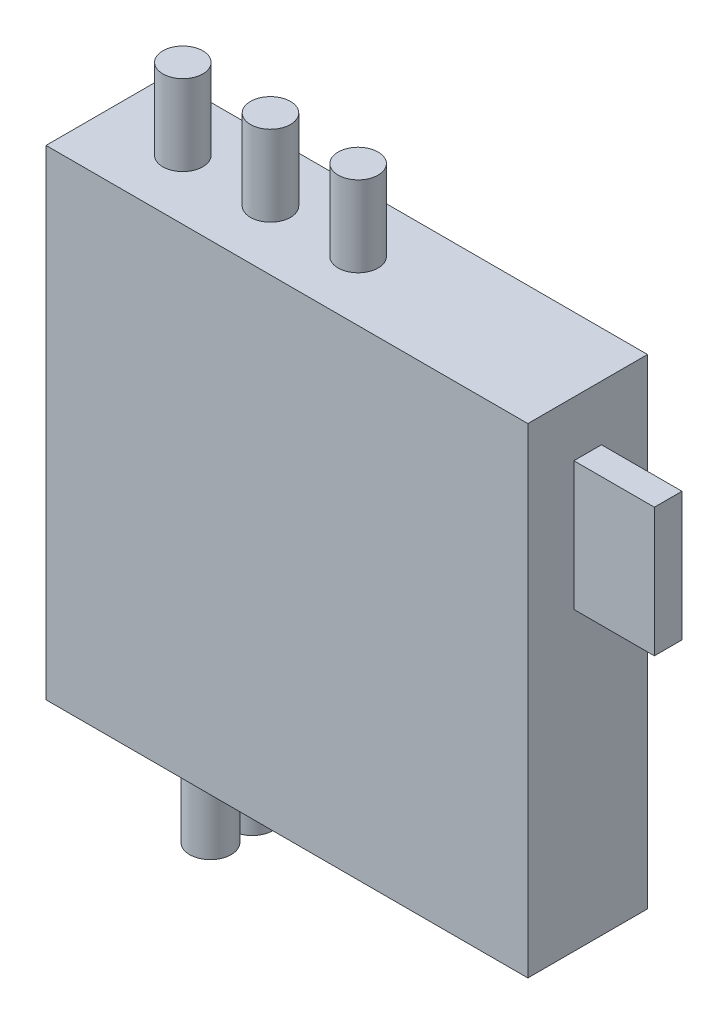
from build123d import *

# Parameters (mm, degrees)
SKETCH1_W           = 52.38
SKETCH1_H           = 13.01
BOSS_EXTRUDE1_DEPTH = 52.2
SKETCH2_R           = 2.26
BOSS_EXTRUDE6_DEPTH = 8.75
SKETCH3_R           = 2.175
BOSS_EXTRUDE7_DEPTH = 8.75
SKETCH4_W           = 3
SKETCH4_H           = 14
BOSS_EXTRUDE8_DEPTH = 8.75


with BuildPart() as part:
    # Sketch1 → Boss-Extrude1 (new body)
    with BuildSketch(Plane(origin=(0, 0, 0), x_dir=(1, 0, 0), z_dir=(0, 1, 0))):
        Rectangle(SKETCH1_W, SKETCH1_H)
    extrude(amount=BOSS_EXTRUDE1_DEPTH)

    # Sketch2 → Boss-Extrude6 (add)
    with BuildSketch(Plane(origin=(0, 0, 0), x_dir=(-1, 0, 0), z_dir=(0, -1, 0))):
        with Locations((12.55, -2.27)):
            Circle(SKETCH2_R)
        with Locations((12.55, 2.27)):
            Circle(SKETCH2_R)
    extrude(amount=BOSS_EXTRUDE6_DEPTH)

    # Sketch3 → Boss-Extrude7 (add)
    with BuildSketch(Plane(origin=(0, 52.2, 0), x_dir=(1, 0, 0), z_dir=(0, 1, 0))):
        with Locations((-17.825, 0)):
            Circle(SKETCH3_R)
        with Locations((-8.295, 0)):
            Circle(SKETCH3_R)
        with Locations((1.235, 0)):
            Circle(SKETCH3_R)
    extrude(amount=BOSS_EXTRUDE7_DEPTH)

    # Sketch4 → Boss-Extrude8 (add)
    with BuildSketch(Plane(origin=(26.19, 0, 0), x_dir=(0, 0, -1), z_dir=(1, 0, 0))):
        with Locations((0, 39.2)):
            Rectangle(SKETCH4_W, SKETCH4_H)
    extrude(amount=BOSS_EXTRUDE8_DEPTH)


solid = part.part
